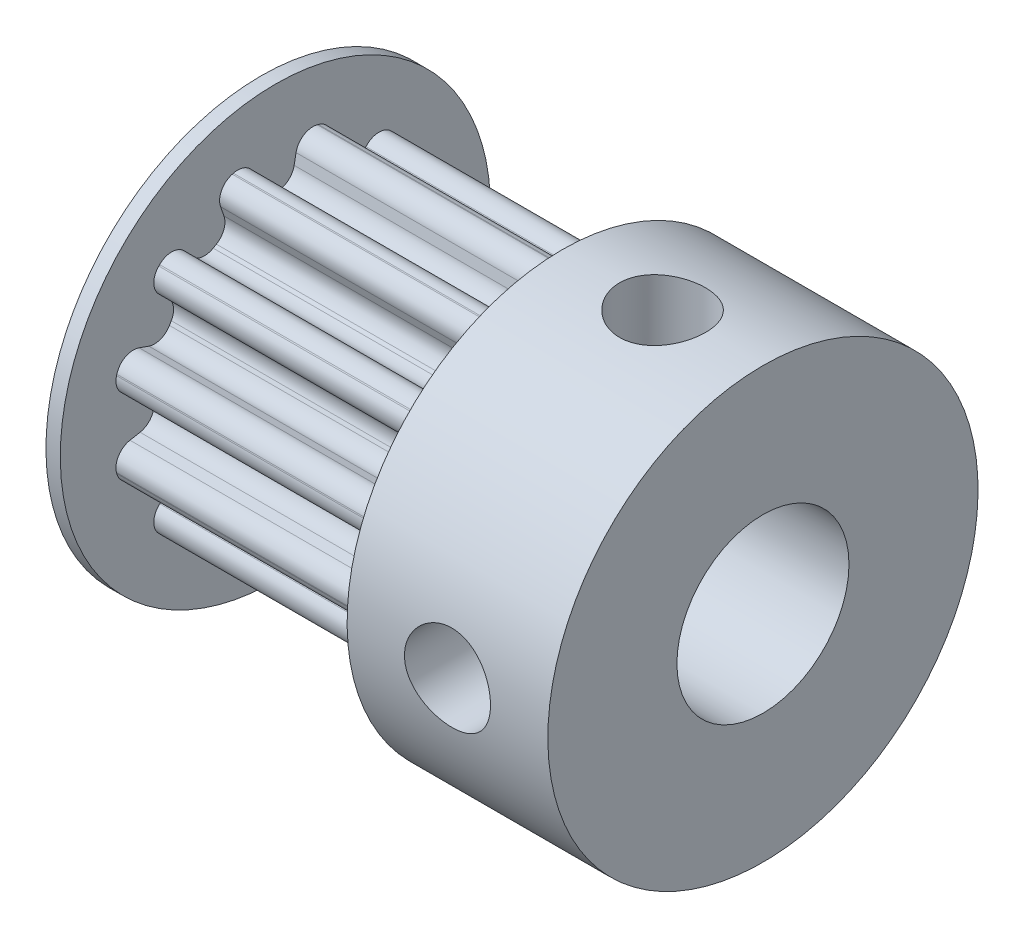
from build123d import *

# Parameters (mm, degrees)
SKETCH3_R                = 3
CUT_EXTRUDE1_DEPTH       = 18.5
SKETCH5_R                = 1.5
CUT_EXTRUDE3_DEPTH       = 10
CIRPATTERN1_COUNT        = 2
CIRPATTERN1_ANGLE        = 90
CUT_EXTRUDE2_DEPTH       = 10
FILLET1_R                = 0.6
CIRPATTERN2_COUNT        = 12
FILLET1_OF_CIRPATTERN2_R = 0.6


with BuildPart() as part:
    # Sketch2 → Revolve1 (revolve)
    with BuildSketch(Plane.XY):
        Polygon((0, 0), (0, 7.5), (0.5, 7.5), (0.5, 5.73), (10.5, 5.73), (10.5, 7.5), (17.5, 7.5), (17.5, 0), align=None)
    revolve(axis=Axis((19.21222629, 0, 0), (-1, 0, 0)))

    # Sketch3 → Cut-Extrude1 (cut, through all)
    with BuildSketch(Plane.ZY):
        Circle(SKETCH3_R)
    extrude(amount=-CUT_EXTRUDE1_DEPTH, mode=Mode.SUBTRACT)

    # Sketch5 → Cut-Extrude3 (cut)
    with BuildSketch(Plane(origin=(0, 0, 0), x_dir=(1, 0, 0), z_dir=(0, 1, 0))):
        with Locations((14, 0)):
            Circle(SKETCH5_R)
    cut_extrude3 = extrude(amount=CUT_EXTRUDE3_DEPTH, mode=Mode.SUBTRACT)

    # CirPattern1: Cut-Extrude3 ×2 about axis
    cirpattern1_axis = Axis((19.21222629, 0, 0), (1, 0, 0))
    for i in range(1, CIRPATTERN1_COUNT):
        add(cut_extrude3.rotate(cirpattern1_axis, i * CIRPATTERN1_ANGLE / (CIRPATTERN1_COUNT - 1)), mode=Mode.SUBTRACT)

    # Sketch4 → Cut-Extrude2 (cut)
    with BuildSketch(Plane(origin=(0.5, 0, 0), x_dir=(0, 0, -1), z_dir=(1, 0, 0))):
        Polygon((1.125, 7.23), (-1.125, 7.23), (-0.5625, 4.23), (0.5625, 4.23), align=None)
    cut_extrude2 = extrude(amount=CUT_EXTRUDE2_DEPTH, mode=Mode.SUBTRACT)

    # Fillet1
    fillet1_edges = [part.edges().sort_by_distance(p)[0] for p in [
        (5.5, 5.669222732, -0.832354262),
        (5.5, 4.23, -0.5625),
        (5.5, 5.669222732, 0.832354262),
        (5.5, 4.23, 0.5625),
    ]]
    fillet(fillet1_edges, radius=FILLET1_R)

    # CirPattern2: Cut-Extrude2 ×12 about axis
    cirpattern2_axis = Axis((0, 0, 0), (1, 0, 0))
    for i in range(1, CIRPATTERN2_COUNT):
        add(cut_extrude2.rotate(cirpattern2_axis, i * 360 / CIRPATTERN2_COUNT), mode=Mode.SUBTRACT)

    # Fillet1 of CirPattern2
    fillet1_of_cirpattern2_edges = [part.edges().sort_by_distance(p)[0] for p in [
        (5.5, 5.325868037, 2.11377143),
        (5.5, 3.944537458, 1.62786071),
        (5.5, 4.493513774, 3.555451302),
        (5.5, 3.382037458, 2.60213929),
        (5.5, 3.555451302, 4.493513774),
        (5.5, 2.60213929, 3.382037458),
        (5.5, 2.11377143, 5.325868037),
        (5.5, 1.62786071, 3.944537458),
        (5.5, 0.832354262, 5.669222732),
        (5.5, 0.5625, 4.23),
        (5.5, -0.832354262, 5.669222732),
        (5.5, -0.5625, 4.23),
        (5.5, -2.11377143, 5.325868037),
        (5.5, -1.62786071, 3.944537458),
        (5.5, -3.555451302, 4.493513774),
        (5.5, -2.60213929, 3.382037458),
        (5.5, -4.493513774, 3.555451302),
        (5.5, -3.382037458, 2.60213929),
        (5.5, -5.325868037, 2.11377143),
        (5.5, -3.944537458, 1.62786071),
        (5.5, -5.669222732, 0.832354262),
        (5.5, -4.23, 0.5625),
        (5.5, -5.669222732, -0.832354262),
        (5.5, -4.23, -0.5625),
        (5.5, -5.325868037, -2.11377143),
        (5.5, -3.944537458, -1.62786071),
        (5.5, -4.493513774, -3.555451302),
        (5.5, -3.382037458, -2.60213929),
        (5.5, -3.555451302, -4.493513774),
        (5.5, -2.60213929, -3.382037458),
        (5.5, -2.11377143, -5.325868037),
        (5.5, -1.62786071, -3.944537458),
        (5.5, -0.832354262, -5.669222732),
        (5.5, -0.5625, -4.23),
        (5.5, 0.832354262, -5.669222732),
        (5.5, 0.5625, -4.23),
        (5.5, 2.11377143, -5.325868037),
        (5.5, 1.62786071, -3.944537458),
        (5.5, 3.555451302, -4.493513774),
        (5.5, 2.60213929, -3.382037458),
        (5.5, 4.493513774, -3.555451302),
        (5.5, 3.382037458, -2.60213929),
        (5.5, 5.325868037, -2.11377143),
        (5.5, 3.944537458, -1.62786071),
    ]]
    fillet(fillet1_of_cirpattern2_edges, radius=FILLET1_OF_CIRPATTERN2_R)


solid = part.part
